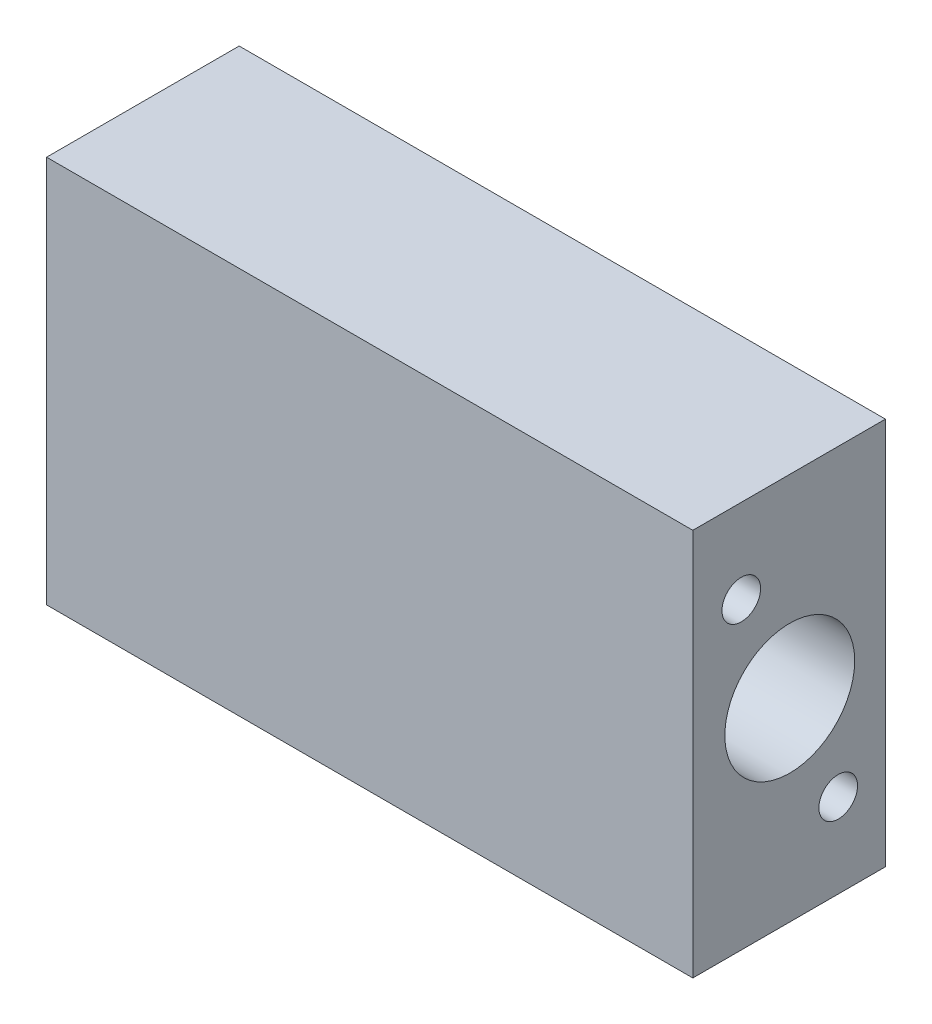
from build123d import *

# Parameters (mm, degrees)
SKETCH1_W                         = 63.5
SKETCH1_H                         = 38.1
BOSS_EXTRUDE1_DEPTH               = 19.05
F_1_2_0_5025_DIAMETER_HOLE1_D     = 12.7635
F_1_2_0_5025_DIAMETER_HOLE1_DEPTH = 57.144535069
F_1_2_0_5025_DIAMETER_HOLE1_TIP   = 3.834542255
F_35_0_11_DIAMETER_HOLE1_D        = 2.794
F_35_0_11_DIAMETER_HOLE1_DEPTH    = 9.652
F_35_0_11_DIAMETER_HOLE1_TIP      = 0.839402285
F_10_24_TAPPED_HOLE1_D            = 3.7973
F_10_24_TAPPED_HOLE1_DEPTH        = 10.035175986
F_10_24_TAPPED_HOLE1_TIP          = 1.140824014
SKETCH9_R                         = 4.7498
BOSS_EXTRUDE2_DEPTH               = 6.35
F_10_24_TAPPED_HOLE2_D            = 3.7973
F_10_24_TAPPED_HOLE2_DEPTH        = 10.414
F_10_24_TAPPED_HOLE2_CSINK_D      = 5.08
F_10_24_TAPPED_HOLE2_CSINK_ANGLE  = 90
F_10_24_TAPPED_HOLE2_TIP          = 1.140824014
CHAMFER1_SIZE                     = 0.127


with BuildPart() as part:
    # Sketch1 → Boss-Extrude1 (new body)
    with BuildSketch(Plane.XY):
        with Locations((-5.976242834, 24.252126053)):
            Rectangle(SKETCH1_W, SKETCH1_H)
    extrude(amount=BOSS_EXTRUDE1_DEPTH)

    # 1/2 (0.5025) Diameter Hole1
    with Locations(Plane(origin=(25.773757166, 0, 0), x_dir=(0, 0, -1), z_dir=(1, 0, 0))):
        with Locations((-9.525, 24.252126053)):
            Hole(F_1_2_0_5025_DIAMETER_HOLE1_D / 2, depth=F_1_2_0_5025_DIAMETER_HOLE1_DEPTH)
            with Locations((0, 0, -(F_1_2_0_5025_DIAMETER_HOLE1_DEPTH + F_1_2_0_5025_DIAMETER_HOLE1_TIP / 2))):  # 118° drill point
                Cone(0, F_1_2_0_5025_DIAMETER_HOLE1_D / 2, F_1_2_0_5025_DIAMETER_HOLE1_TIP, mode=Mode.SUBTRACT)

    # #35 (0.11) Diameter Hole1
    with Locations(Plane(origin=(0, 0, 0), x_dir=(-1, 0, 0), z_dir=(0, 0, -1))):
        with Locations((26.250138314, 20.873926053), (26.250138314, 27.630326053), (-14.435604522, 27.630326053), (-14.435604522, 20.873926053)):
            Hole(F_35_0_11_DIAMETER_HOLE1_D / 2, depth=F_35_0_11_DIAMETER_HOLE1_DEPTH)
            with Locations((0, 0, -(F_35_0_11_DIAMETER_HOLE1_DEPTH + F_35_0_11_DIAMETER_HOLE1_TIP / 2))):  # 118° drill point
                Cone(0, F_35_0_11_DIAMETER_HOLE1_D / 2, F_35_0_11_DIAMETER_HOLE1_TIP, mode=Mode.SUBTRACT)

    # #10-24 Tapped Hole1
    with Locations(Plane(origin=(25.773757166, 0, 0), x_dir=(0, 0, -1), z_dir=(1, 0, 0))):
        with Locations((-4.7625, 13.478578619), (-14.2875, 35.025673487)):
            Hole(F_10_24_TAPPED_HOLE1_D / 2, depth=F_10_24_TAPPED_HOLE1_DEPTH)
            with Locations((0, 0, -(F_10_24_TAPPED_HOLE1_DEPTH + F_10_24_TAPPED_HOLE1_TIP / 2))):  # 118° drill point
                Cone(0, F_10_24_TAPPED_HOLE1_D / 2, F_10_24_TAPPED_HOLE1_TIP, mode=Mode.SUBTRACT)

    # Sketch9 → Boss-Extrude2 (add)
    with BuildSketch(Plane(origin=(0, 0, 0), x_dir=(-1, 0, 0), z_dir=(0, 0, -1))):
        with Locations((10.738742834, 24.252126053)):
            Circle(SKETCH9_R)
    extrude(amount=BOSS_EXTRUDE2_DEPTH)

    # #10-24 Tapped Hole2
    with Locations(Plane(origin=(0, 0, -6.35), x_dir=(-1, 0, 0), z_dir=(0, 0, -1))):
        with Locations((10.738742834, 24.252126053)):
            CounterSinkHole(F_10_24_TAPPED_HOLE2_D / 2, F_10_24_TAPPED_HOLE2_CSINK_D / 2, depth=F_10_24_TAPPED_HOLE2_DEPTH, counter_sink_angle=F_10_24_TAPPED_HOLE2_CSINK_ANGLE)
            with Locations((0, 0, -(F_10_24_TAPPED_HOLE2_DEPTH + F_10_24_TAPPED_HOLE2_TIP / 2))):  # 118° drill point
                Cone(0, F_10_24_TAPPED_HOLE2_D / 2, F_10_24_TAPPED_HOLE2_TIP, mode=Mode.SUBTRACT)

    # Chamfer1
    chamfer1_edges = [part.edges().sort_by_distance(p)[0] for p in [
        (13.038604522, 20.873926053, 0),
        (13.038604522, 27.630326053, 0),
        (-27.647138314, 27.630326053, 0),
        (-27.647138314, 20.873926053, 0),
        (-37.726242834, 24.252126053, 0),
        (-5.976242834, 43.302126053, 0),
        (-5.988942834, 24.252126053, -6.35),
        (25.773757166, 24.252126053, 0),
        (-5.976242834, 5.202126053, 0),
    ]]
    chamfer(chamfer1_edges, length=CHAMFER1_SIZE)


solid = part.part
